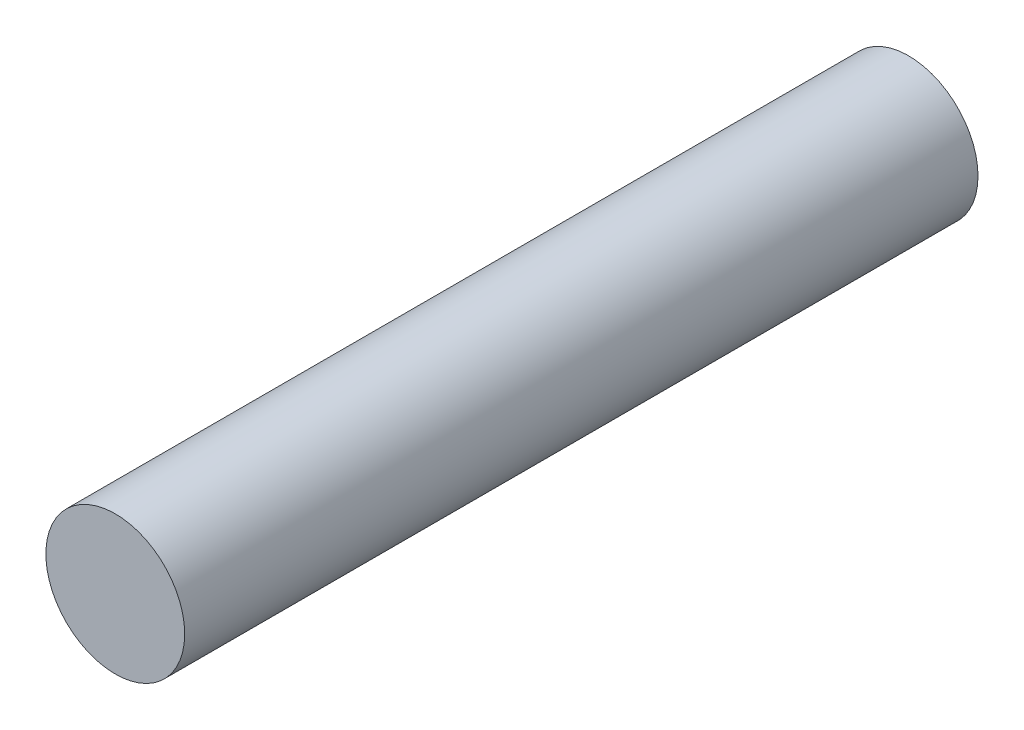
from build123d import *

# Parameters (mm, degrees)
IZIM1_R                     = 3.5
Y_KSEKLIK_EKSTR_ZYON1_DEPTH = 40


with BuildPart() as part:
    # Çizim1 → Yükseklik-Ekstrüzyon1 (new body)
    with BuildSketch(Plane.XY):
        Circle(IZIM1_R)
    extrude(amount=Y_KSEKLIK_EKSTR_ZYON1_DEPTH)


solid = part.part
